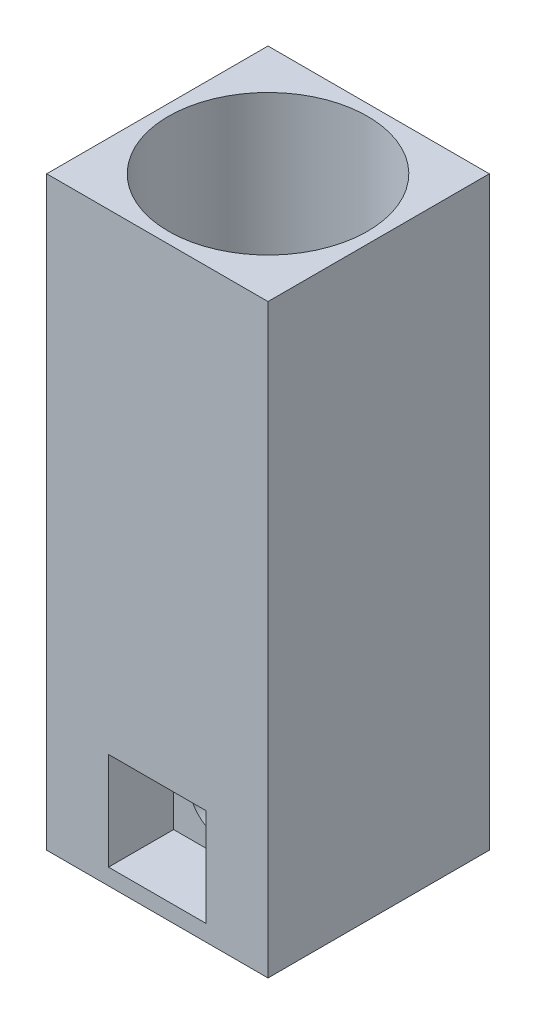
from build123d import *

# Parameters (mm, degrees)
SKETCH1_W           = 21.59
SKETCH1_H           = 21.59
BOSS_EXTRUDE1_DEPTH = 57.15
SKETCH2_W           = 9.525
SKETCH2_H           = 9.525
CUT_EXTRUDE1_DEPTH  = 6.35
SKETCH3_R           = 3.302
CUT_EXTRUDE2_DEPTH  = 16.24
SKETCH4_R           = 9.7155
CUT_EXTRUDE3_DEPTH  = 31.75


with BuildPart() as part:
    # Sketch1 → Boss-Extrude1 (new body)
    with BuildSketch(Plane(origin=(0, 0, 0), x_dir=(1, 0, 0), z_dir=(0, 1, 0))):
        Rectangle(SKETCH1_W, SKETCH1_H)
    extrude(amount=BOSS_EXTRUDE1_DEPTH)

    # Sketch2 → Cut-Extrude1 (cut)
    with BuildSketch(Plane.XY.offset(10.795)):
        with Locations((0, 6.35)):
            Rectangle(SKETCH2_W, SKETCH2_H)
    extrude(amount=-CUT_EXTRUDE1_DEPTH, mode=Mode.SUBTRACT)

    # Sketch3 → Cut-Extrude2 (cut, through all)
    with BuildSketch(Plane.XY.offset(4.445)):
        with Locations((0, 6.35)):
            Circle(SKETCH3_R)
    extrude(amount=-CUT_EXTRUDE2_DEPTH, mode=Mode.SUBTRACT)

    # Sketch4 → Cut-Extrude3 (cut)
    with BuildSketch(Plane(origin=(0, 57.15, 0), x_dir=(1, 0, 0), z_dir=(0, 1, 0))):
        Circle(SKETCH4_R)
    extrude(amount=-CUT_EXTRUDE3_DEPTH, mode=Mode.SUBTRACT)


solid = part.part
